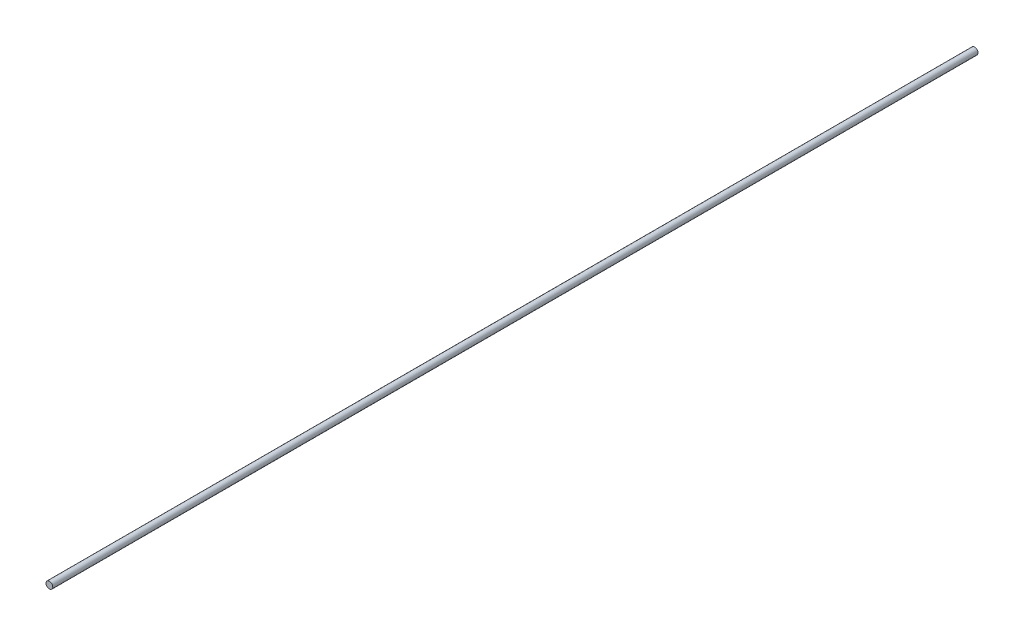
from build123d import *

# Parameters (mm, degrees)
SKETCH1_R           = 1.5
BOSS_EXTRUDE1_DEPTH = 410


with BuildPart() as part:
    # Sketch1 → Boss-Extrude1 (new body)
    with BuildSketch(Plane.XY):
        Circle(SKETCH1_R)
    extrude(amount=BOSS_EXTRUDE1_DEPTH)


solid = part.part
